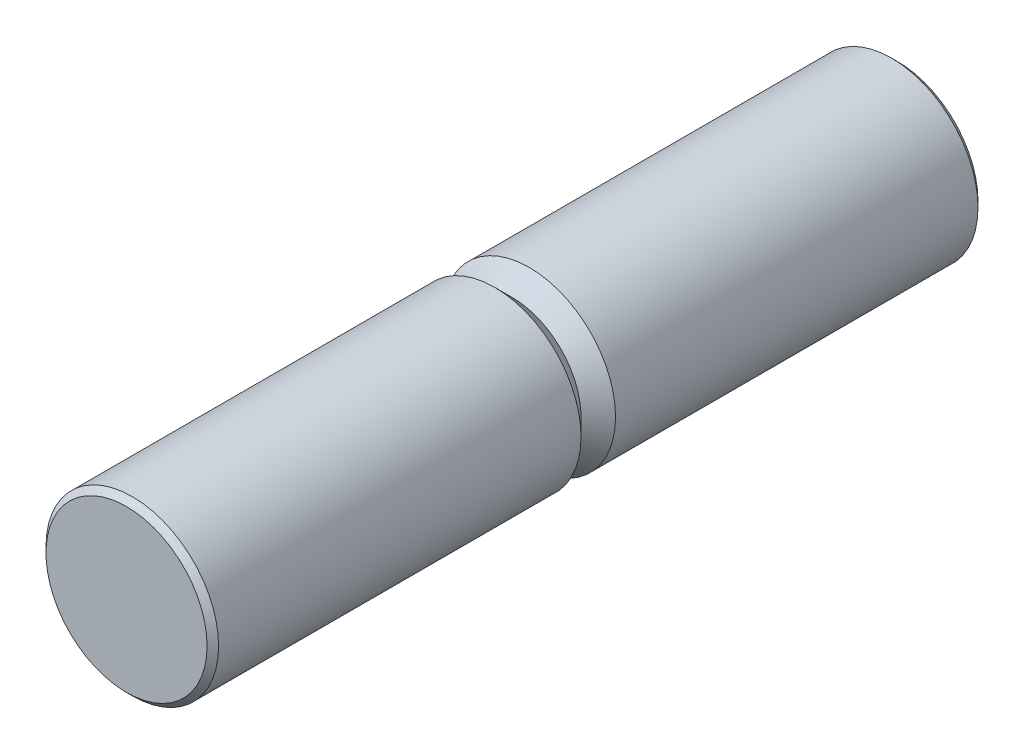
from build123d import *

# Parameters (mm, degrees)
DIA_CYLINDRE_R = 7.5
CYLINDRE_DEPTH = 33.5
CHANFREIN_SIZE = 0.5


with BuildPart() as part:
    # Dia cylindre → Cylindre (new body, symmetric)
    with BuildSketch(Plane.XY):
        Circle(DIA_CYLINDRE_R)
    extrude(amount=CYLINDRE_DEPTH, both=True)

    # Chanfrein
    chanfrein_edges = [part.edges().sort_by_distance(p)[0] for p in [
        (-7.5, 0, -33.5),
        (-7.5, 0, 33.5),
    ]]
    chamfer(chanfrein_edges, length=CHANFREIN_SIZE)

    # Profil rainure → Rainure (revolve, cut)
    with BuildSketch(Plane(origin=(0, 0, 0), x_dir=(1, 0, 0), z_dir=(0, 1, 0))):
        Polygon((-7.5, 1.5), (-7.5, -1.5), (-6, 0), align=None)
    revolve(axis=Axis((0, 0, -36.430134701), (0, 0, 1)), mode=Mode.SUBTRACT)


solid = part.part
